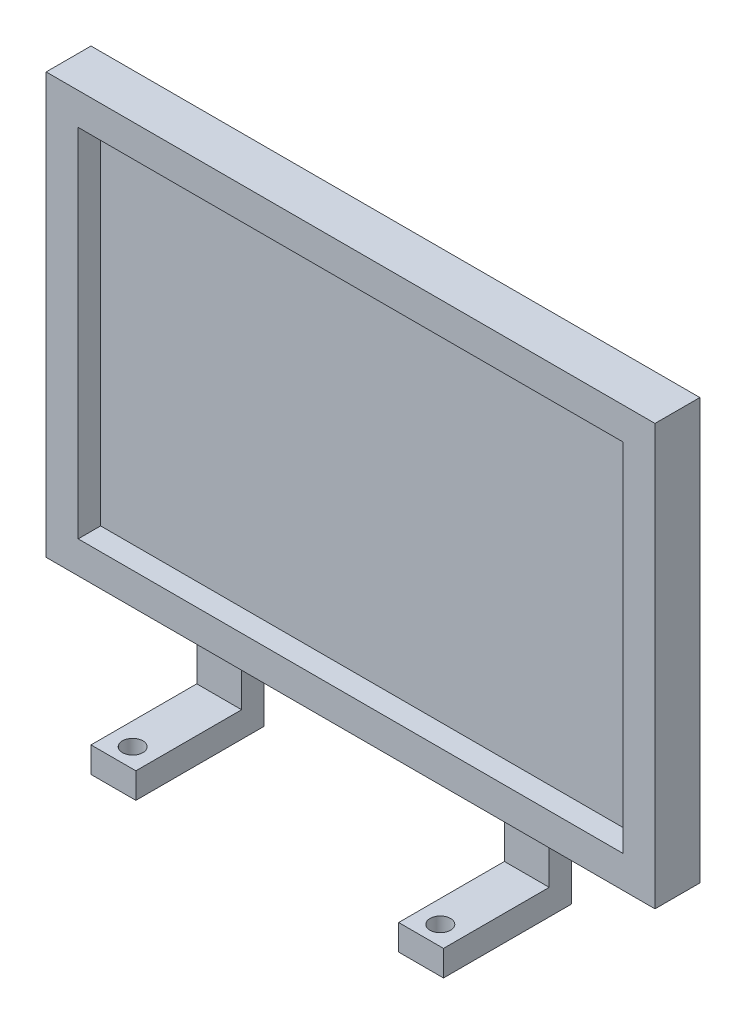
from build123d import *

# Parameters (mm, degrees)
SKETCH1_W           = 85
SKETCH1_H           = 55.6
BOSS_EXTRUDE1_DEPTH = 3.5
SKETCH1_4_W         = 85
SKETCH1_4_H         = 55.6
BOSS_EXTRUDE2_DEPTH = 7
SKETCH1_5_W         = 7
SKETCH1_5_H         = 8.84
BOSS_EXTRUDE3_DEPTH = 3.5
SKETCH1_6_W         = 7
SKETCH1_6_H         = 4
BOSS_EXTRUDE4_DEPTH = 20
SKETCH2_R           = 1.6
CUT_EXTRUDE1_DEPTH  = 94.85671846


with BuildPart() as part:
    # Sketch1 → Boss-Extrude1 (new body)
    with BuildSketch(Plane.XY):
        Rectangle(SKETCH1_W, SKETCH1_H)
    extrude(amount=BOSS_EXTRUDE1_DEPTH)

    # Sketch1_4 → Boss-Extrude2 (add)
    with BuildSketch(Plane.XY):
        Polygon((47.5, 32.8), (-47.5, 32.8), (-47.5, -32.8), (-27.5, -32.8), (-20.5, -32.8), (20.5, -32.8), (27.5, -32.8), (47.5, -32.8), align=None)
        Rectangle(SKETCH1_4_W, SKETCH1_4_H, mode=Mode.SUBTRACT)
    extrude(amount=BOSS_EXTRUDE2_DEPTH)

    # Sketch1_5 → Boss-Extrude3 (add)
    with BuildSketch(Plane.XY):
        with Locations((-24, -37.22)):
            Rectangle(SKETCH1_5_W, SKETCH1_5_H)
        with Locations((24, -37.22)):
            Rectangle(SKETCH1_5_W, SKETCH1_5_H)
    extrude(amount=BOSS_EXTRUDE3_DEPTH)

    # Sketch1_6 → Boss-Extrude4 (add)
    with BuildSketch(Plane.XY):
        with Locations((-24, -43.64)):
            Rectangle(SKETCH1_6_W, SKETCH1_6_H)
        with Locations((24, -43.64)):
            Rectangle(SKETCH1_6_W, SKETCH1_6_H)
    extrude(amount=BOSS_EXTRUDE4_DEPTH)

    # Sketch2 → Cut-Extrude1 (cut, symmetric)
    with BuildSketch(Plane(origin=(0, -45.64, 0), x_dir=(-1, 0, 0), z_dir=(0, -1, 0))):
        with Locations((24, -17)):
            Circle(SKETCH2_R)
    cut_extrude1 = extrude(amount=CUT_EXTRUDE1_DEPTH, both=True, mode=Mode.SUBTRACT)

    # Mirror1: Cut-Extrude1 across plane
    add(cut_extrude1.mirror(Plane(origin=(0, 0, 0), x_dir=(0, 0, 1), z_dir=(1, 0, 0))), mode=Mode.SUBTRACT)


solid = part.part
